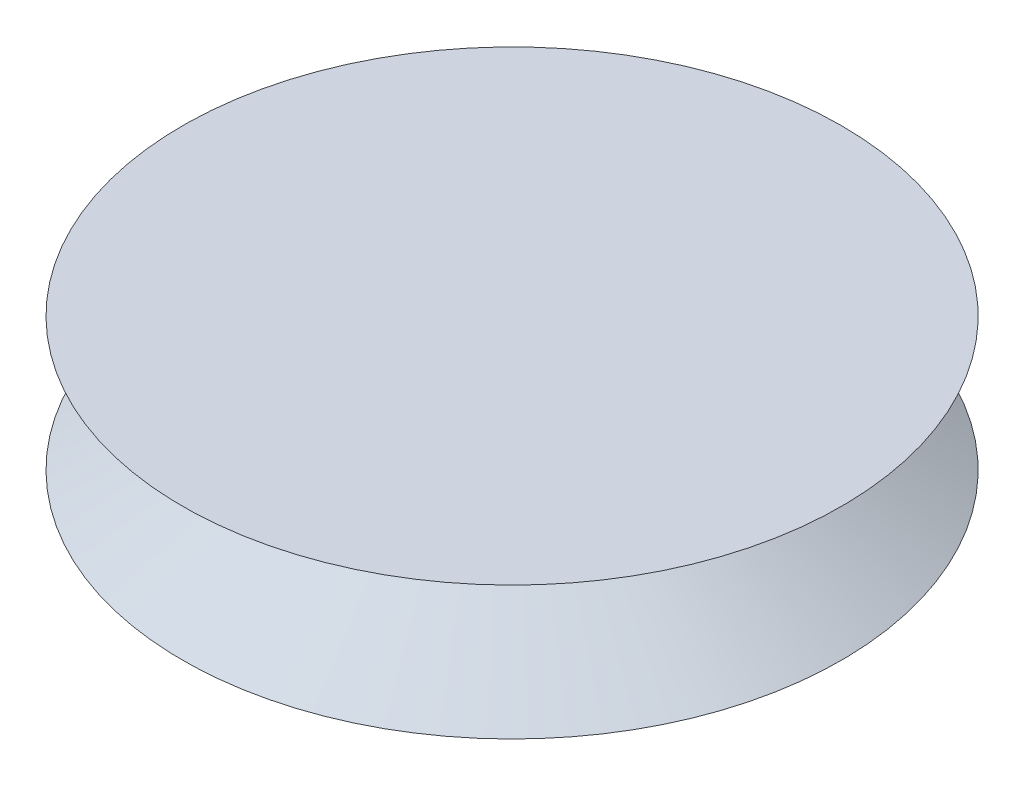
from build123d import *


with BuildPart() as part:
    # Sketch3 → Revolve4 (revolve)
    with BuildSketch(Plane.XY):
        Polygon((-131.423915741, 48.674236442), (-68.935789815, 48.674236442), (-68.935789815, 73.948096291), (-131.423915741, 73.948096291), (-107.145089744, 63.201730686), align=None)
    revolve(axis=Axis((-68.935789815, 48.674236442, 0), (0, 1, 0)))


solid = part.part
